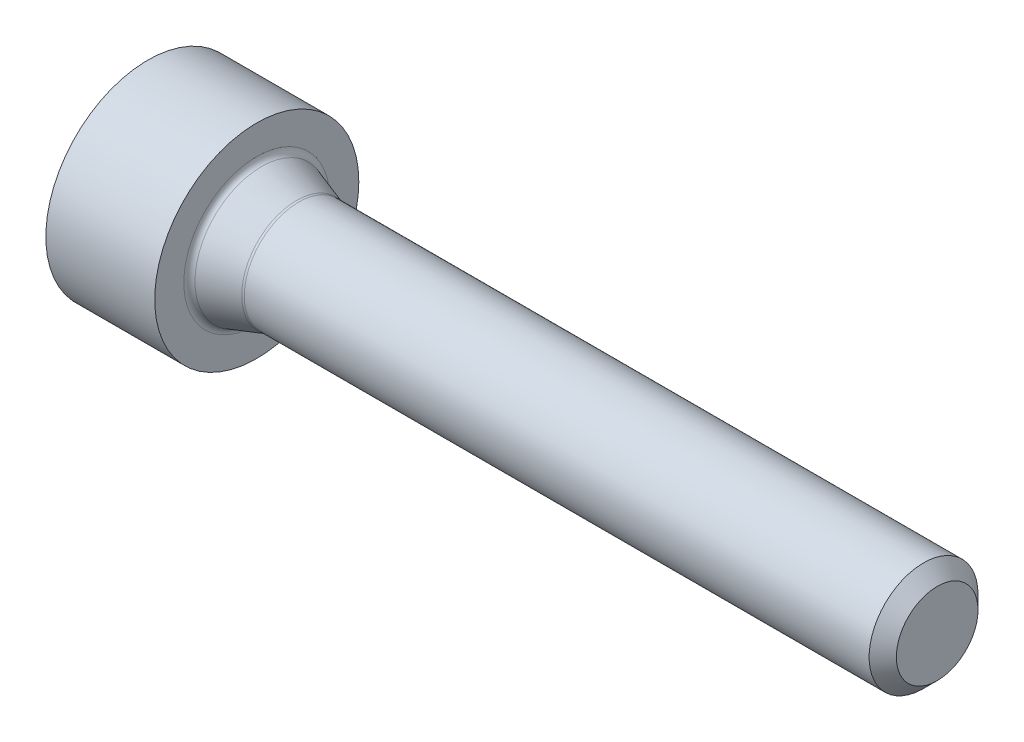
from build123d import *

# Parameters (mm, degrees)
FILLET_1_R          = 0.1
CHAMFER_1_SIZE      = 0.2
CUT_EXTRUDE_1_DEPTH = 0.7


with BuildPart() as part:
    # Эскиз1 → Повернуть1 (revolve)
    with BuildSketch(Plane.XY):
        Polygon((0, 0), (0, 1.5), (1.6, 1.5), (1.6, 1), (2.2, 0.8), (11.6, 0.8), (11.6, 0), align=None)
    revolve(axis=Axis((0, 0, 0), (-1, 0, 0)))

    # Скругление1
    fillet_1_edges = [part.edges().sort_by_distance(p)[0] for p in [
        (2.2, -0.8, 0),
        (1.6, -1, 0),
    ]]
    fillet(fillet_1_edges, radius=FILLET_1_R)

    # Фаска1
    chamfer_1_edges = [part.edges().sort_by_distance(p)[0] for p in [
        (11.6, -0.8, 0),
    ]]
    chamfer(chamfer_1_edges, length=CHAMFER_1_SIZE)

    # Эскиз2 → Вырез-Вытянуть1 (cut)
    with BuildSketch(Plane.ZY):
        Polygon((0, 0.8665), (-0.750411012, 0.43325), (-0.750411012, -0.43325), (0, -0.8665), (0.750411012, -0.43325), (0.750411012, 0.43325), align=None)
    extrude(amount=-CUT_EXTRUDE_1_DEPTH, mode=Mode.SUBTRACT)


solid = part.part
